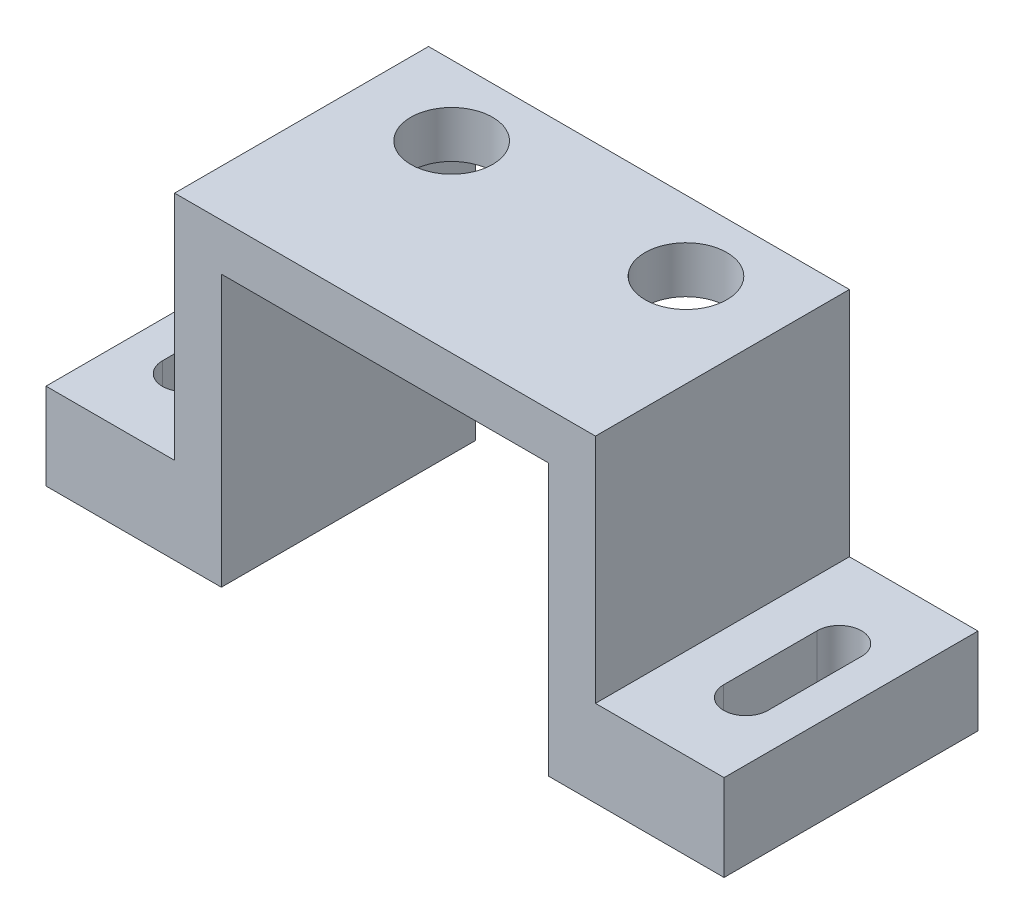
from build123d import *

# Parameters (mm, degrees)
SKETCH3_W           = 18
SKETCH3_H           = 6
BOSS_EXTRUDE1_DEPTH = 2
SKETCH4_R           = 1.75
CUT_EXTRUDE1_DEPTH  = 3
SKETCH5_W           = 18
SKETCH5_H           = 4.86
BOSS_EXTRUDE4_DEPTH = 2
SKETCH6_W           = 2
SKETCH6_H           = 10.86
BOSS_EXTRUDE5_DEPTH = 11.6
SKETCH7_W           = 10.86
SKETCH7_H           = 3.7
BOSS_EXTRUDE6_DEPTH = 5.5
CUT_EXTRUDE2_DEPTH  = 4.7


with BuildPart() as part:
    # Sketch3 → Boss-Extrude1 (new body)
    with BuildSketch(Plane(origin=(0, 0, 0), x_dir=(1, 0, 0), z_dir=(0, 1, 0))):
        Rectangle(SKETCH3_W, SKETCH3_H)
    extrude(amount=BOSS_EXTRUDE1_DEPTH)

    # Sketch4 → Cut-Extrude1 (cut, through all)
    with BuildSketch(Plane(origin=(0, 2, 0), x_dir=(1, 0, 0), z_dir=(0, 1, 0))):
        with Locations((-5.01, 0)):
            Circle(SKETCH4_R)
        with Locations((5.01, 0)):
            Circle(SKETCH4_R)
    extrude(amount=-CUT_EXTRUDE1_DEPTH, mode=Mode.SUBTRACT)

    # Sketch5 → Boss-Extrude4 (add)
    with BuildSketch(Plane(origin=(0, 0, 0), x_dir=(1, 0, 0), z_dir=(0, 1, 0))):
        with Locations((0, -5.43)):
            Rectangle(SKETCH5_W, SKETCH5_H)
    boss_extrude4 = extrude(amount=BOSS_EXTRUDE4_DEPTH)

    # Sketch6 → Boss-Extrude5 (add)
    with BuildSketch(Plane.XZ):
        with Locations((-8, 2.43)):
            Rectangle(SKETCH6_W, SKETCH6_H)
    boss_extrude5 = extrude(amount=BOSS_EXTRUDE5_DEPTH)

    # Sketch7 → Boss-Extrude6 (add)
    with BuildSketch(Plane.ZY.offset(9)):
        with Locations((2.43, -9.75)):
            Rectangle(SKETCH7_W, SKETCH7_H)
    boss_extrude6 = extrude(amount=BOSS_EXTRUDE6_DEPTH)

    # Sketch8 → Cut-Extrude2 (cut, through all)
    with BuildSketch(Plane(origin=(0, -7.9, 0), x_dir=(1, 0, 0), z_dir=(0, 1, 0))):
        with BuildLine():
            Line((-11.05, -0.43), (-11.05, -4.43))
            ThreePointArc((-11.05, -4.43), (-12, -5.38), (-12.95, -4.43))
            Line((-12.95, -4.43), (-12.95, -0.43))
            ThreePointArc((-12.95, -0.43), (-12, 0.52), (-11.05, -0.43))
        make_face()
    cut_extrude2 = extrude(amount=-CUT_EXTRUDE2_DEPTH, mode=Mode.SUBTRACT)

    # Mirror1: Boss-Extrude4, Boss-Extrude5, Boss-Extrude6, Cut-Extrude2 across plane
    add(boss_extrude4.mirror(Plane(origin=(0, 0, 0), x_dir=(0, 0, 1), z_dir=(1, 0, 0))))
    add(boss_extrude5.mirror(Plane(origin=(0, 0, 0), x_dir=(0, 0, 1), z_dir=(1, 0, 0))))
    add(boss_extrude6.mirror(Plane(origin=(0, 0, 0), x_dir=(0, 0, 1), z_dir=(1, 0, 0))))
    add(cut_extrude2.mirror(Plane(origin=(0, 0, 0), x_dir=(0, 0, 1), z_dir=(1, 0, 0))), mode=Mode.SUBTRACT)


solid = part.part
